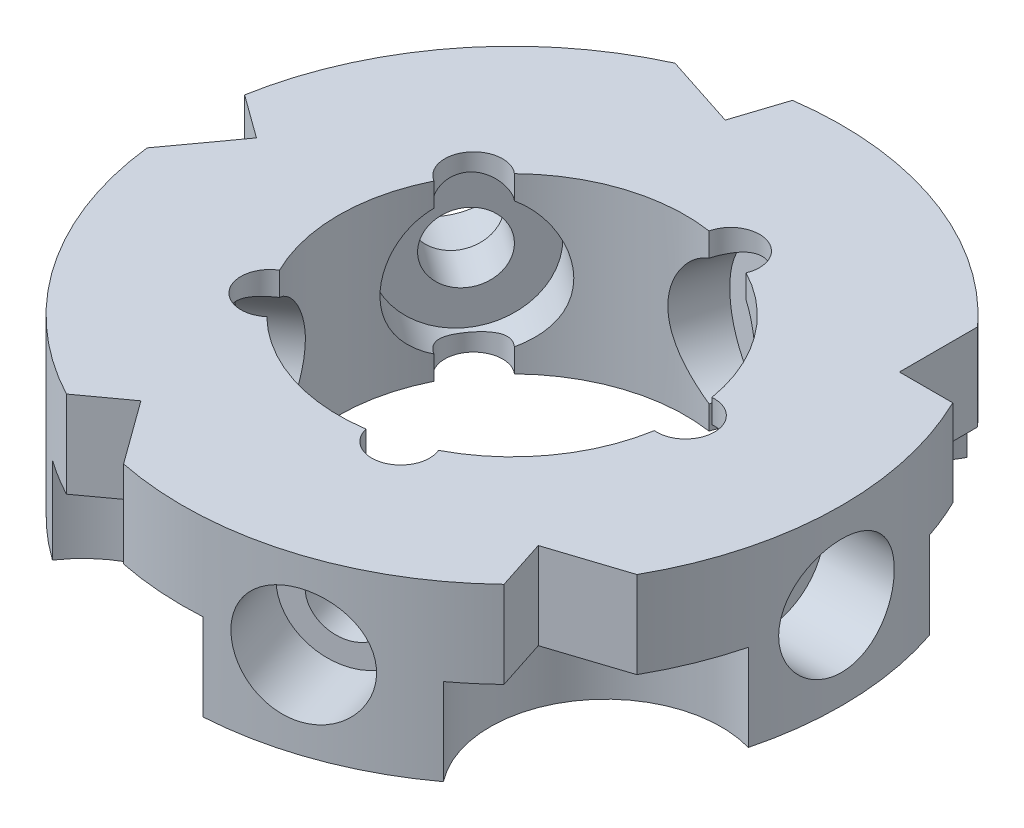
from build123d import *

# Parameters (mm, degrees)
SKETCH1_R           = 28.5
SKETCH1_R_2         = 15
BOSS_EXTRUDE1_DEPTH = 7.5
CUT_EXTRUDE1_DEPTH  = 8.5000001
SKETCH5_R           = 2.5
CUT_EXTRUDE2_DEPTH  = 8.5000001
CUT_EXTRUDE4_DEPTH  = 7.5
CIRPATTERN1_COUNT   = 5


with BuildPart() as part:
    # Sketch1 → Boss-Extrude1 (new body, symmetric)
    with BuildSketch(Plane(origin=(0, 0, 0), x_dir=(1, 0, 0), z_dir=(0, 1, 0))):
        with Locations(Location((0, 0, 0), (0, 0, 270))):  # turned: the seam where the file's is
            Circle(SKETCH1_R)
        with Locations(Location((0, 0, 0), (0, 0, 270))):  # turned: the seam where the file's is
            Circle(SKETCH1_R_2, mode=Mode.SUBTRACT)
    extrude(amount=BOSS_EXTRUDE1_DEPTH, both=True)

    # Sketch3 → Cut-Revolve1 (revolve, cut)
    with BuildSketch(Plane.XY, mode=Mode.PRIVATE) as cut_revolve1_sk:
        Polygon((0, 0), (0, 6), (18, 6), (18, 3), (22, 3), (22, 5), (28.5, 5), (28.5, 0), align=None)
    cut_revolve1 = revolve(cut_revolve1_sk.sketch.rotate(Axis((0, 0, 0), (1, 0, 0)), 90), axis=Axis((0, 0, 0), (1, 0, 0)), mode=Mode.SUBTRACT)  # turned: the seam where the file's is

    # Sketch4 → Cut-Extrude1 (cut, symmetric)
    with BuildSketch(Plane(origin=(0, 0, 0), x_dir=(1, 0, 0), z_dir=(0, 1, 0))):
        with BuildLine():
            Line((21, 19.267848868), (21, 12.5))
            Line((21, 12.5), (25.61249695, 12.5))
            ThreePointArc((25.61249695, 12.5), (23.55062977, 16.050477795), (21, 19.267848868))
        make_face()
    cut_extrude1 = extrude(amount=CUT_EXTRUDE1_DEPTH, both=True, mode=Mode.SUBTRACT)

    # Sketch5 → Cut-Extrude2 (cut, symmetric)
    with BuildSketch(Plane(origin=(0, 0, 0), x_dir=(1, 0, 0), z_dir=(0, 1, 0))):
        with Locations((15, 0)):
            Circle(SKETCH5_R)
    cut_extrude2 = extrude(amount=CUT_EXTRUDE2_DEPTH, both=True, mode=Mode.SUBTRACT)

    # Sketch6 → Cut-Extrude4 (cut)
    with BuildSketch(Plane.XZ.offset(7.5)):
        with BuildLine():
            ThreePointArc((27.021938787, -9.058963747), (15.760215072, -12.313229507), (15.327072463, -24.027710039))
            ThreePointArc((15.327072463, -24.027710039), (22.458306478, -17.546352047), (27.021938787, -9.058963747))
        make_face()
    cut_extrude4 = extrude(amount=-CUT_EXTRUDE4_DEPTH, mode=Mode.SUBTRACT)

    # CirPattern1: Cut-Revolve1, Cut-Extrude1, Cut-Extrude2, Cut-Extrude4 ×5 about axis
    cirpattern1_axis = Axis((0, 0, 0), (0, 1, 0))
    add([cut_revolve1.rotate(cirpattern1_axis, i * 360 / CIRPATTERN1_COUNT) for i in range(1, CIRPATTERN1_COUNT)], mode=Mode.SUBTRACT)
    add([cut_extrude1.rotate(cirpattern1_axis, i * 360 / CIRPATTERN1_COUNT) for i in range(1, CIRPATTERN1_COUNT)], mode=Mode.SUBTRACT)
    add([cut_extrude2.rotate(cirpattern1_axis, i * 360 / CIRPATTERN1_COUNT) for i in range(1, CIRPATTERN1_COUNT)], mode=Mode.SUBTRACT)
    add([cut_extrude4.rotate(cirpattern1_axis, i * 360 / CIRPATTERN1_COUNT) for i in range(1, CIRPATTERN1_COUNT)], mode=Mode.SUBTRACT)


solid = part.part
